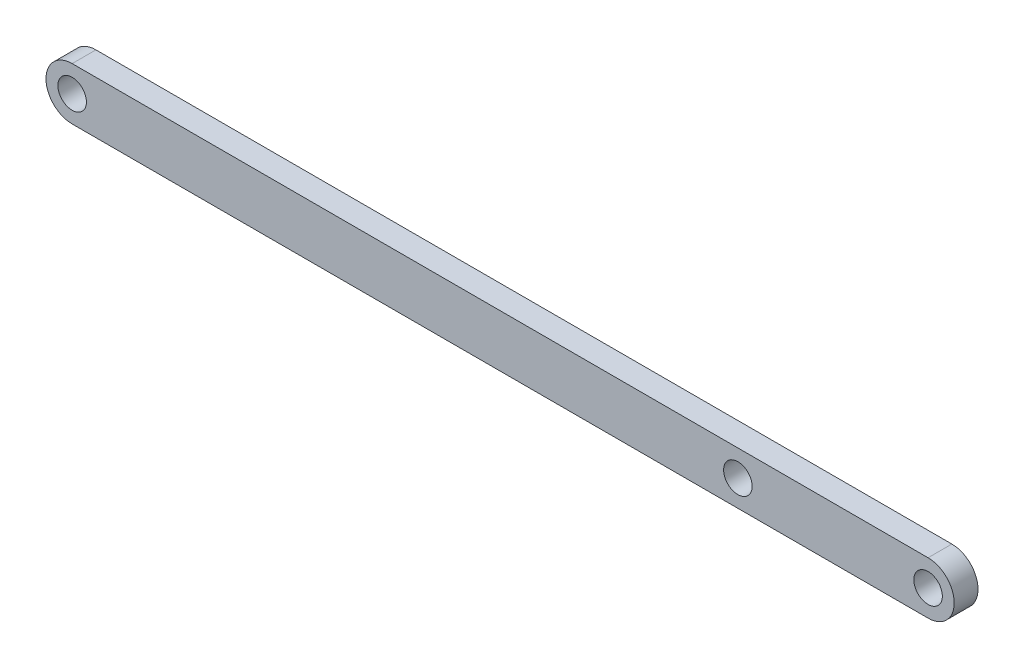
from build123d import *

# Parameters (mm, degrees)
SKETCH1_R           = 3
BOSS_EXTRUDE1_DEPTH = 2.5


with BuildPart() as part:
    # Sketch1 → Boss-Extrude1 (new body, symmetric)
    with BuildSketch(Plane.XY):
        with BuildLine():
            Line((-90, 5.5), (90, 5.5))
            ThreePointArc((90, 5.5), (95.5, 0), (90, -5.5))
            Line((90, -5.5), (-90, -5.5))
            ThreePointArc((-90, -5.5), (-95.5, 0), (-90, 5.5))
        make_face()
        with Locations((-90, 0)):
            Circle(SKETCH1_R, mode=Mode.SUBTRACT)
        with Locations((90, 0)):
            Circle(SKETCH1_R, mode=Mode.SUBTRACT)
        with Locations((50, 0)):
            Circle(SKETCH1_R, mode=Mode.SUBTRACT)
    extrude(amount=BOSS_EXTRUDE1_DEPTH, both=True)


solid = part.part
